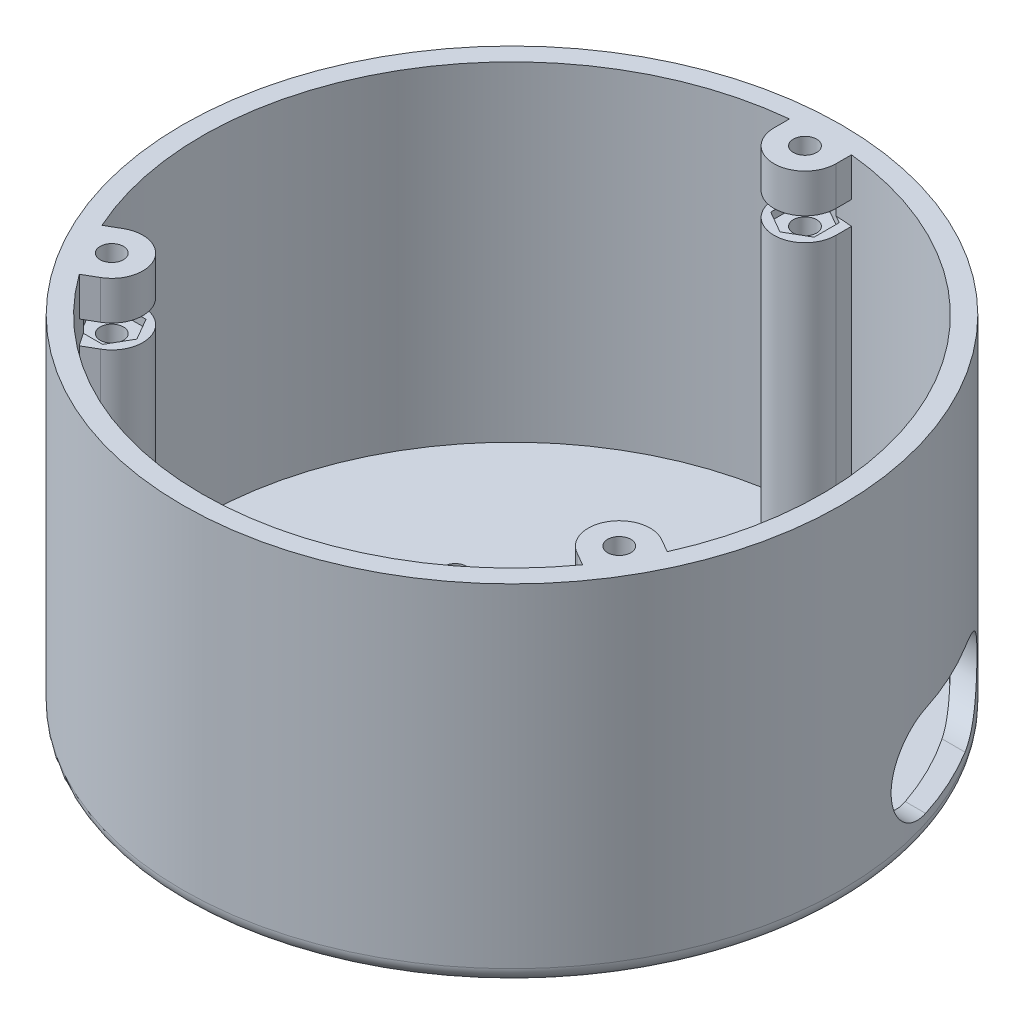
from build123d import *

# Parameters (mm, degrees)
SKETCH1_R           = 42.5
BOSS_EXTRUDE1_DEPTH = 45
FILLET1_R           = 2
SHELL1_T            = -2.5
SKETCH2_R           = 1.5
BOSS_EXTRUDE2_DEPTH = 42.5
CUT_EXTRUDE1_START  = -3
CUT_EXTRUDE1_DEPTH  = 6
CUT_EXTRUDE2_START  = -5
SKETCH4_R           = 40
CUT_EXTRUDE2_DEPTH  = 3
CUT_EXTRUDE3_DEPTH  = 120
SKETCH7_R           = 1.5
CUT_EXTRUDE4_DEPTH  = 10


with BuildPart() as part:
    # Sketch1 → Boss-Extrude1 (new body)
    with BuildSketch(Plane(origin=(0, 0, 0), x_dir=(1, 0, 0), z_dir=(0, 1, 0))):
        with Locations(Location((0, 0, 0), (0, 0, 90))):
            Circle(SKETCH1_R)
    extrude(amount=BOSS_EXTRUDE1_DEPTH)

    # Fillet1
    fillet1_edges = [part.edges().sort_by_distance(p)[0] for p in [
        (0, 0, 42.5),
    ]]
    fillet(fillet1_edges, radius=FILLET1_R)

    # Shell1
    shell1_openings = [part.faces().sort_by_distance(p)[0] for p in [
        (0, 45, 0),
    ]]
    offset(amount=SHELL1_T, openings=shell1_openings, kind=Kind.INTERSECTION)

    # Sketch2 → Boss-Extrude2 (add)
    with BuildSketch(Plane(origin=(0, 2.5, 0), x_dir=(1, 0, 0), z_dir=(0, 1, 0))):
        with BuildLine():
            Line((-34.080943597, -24.295444113), (-30.735760263, -22.364101615))
            ThreePointArc((-30.735760263, -22.364101615), (-29.271658648, -16.9), (-34.735760263, -15.435898385))
            Line((-34.735760263, -15.435898385), (-38.080943597, -17.367240883))
            Line((-38.080943597, -17.367240883), (-34.080943597, -24.295444113))
        make_face()
        with Locations(Location((-32.735760263, -18.9, 0), (0, 0, 90))):
            Circle(SKETCH2_R, mode=Mode.SUBTRACT)
        with BuildLine():
            Line((38.080943597, -17.367240883), (34.735760263, -15.435898385))
            ThreePointArc((34.735760263, -15.435898385), (29.271658648, -16.9), (30.735760263, -22.364101615))
            Line((30.735760263, -22.364101615), (34.080943597, -24.295444113))
            Line((34.080943597, -24.295444113), (38.080943597, -17.367240883))
        make_face()
        with Locations(Location((32.735760263, -18.9, 0), (0, 0, 90))):
            Circle(SKETCH2_R, mode=Mode.SUBTRACT)
        with BuildLine():
            Line((-4, 41.662684996), (-4, 37.8))
            ThreePointArc((-4, 37.8), (0, 33.8), (4, 37.8))
            Line((4, 37.8), (4, 41.662684996))
            Line((4, 41.662684996), (-4, 41.662684996))
        make_face()
        with Locations(Location((0, 37.8, 0), (0, 0, 90))):
            Circle(SKETCH2_R, mode=Mode.SUBTRACT)
    extrude(amount=BOSS_EXTRUDE2_DEPTH)

    # Sketch3 → Cut-Extrude1 (cut)
    with BuildSketch(Plane(origin=(0, 45, 0), x_dir=(1, 0, 0), z_dir=(0, 1, 0)).offset(CUT_EXTRUDE1_START)):
        Polygon((-31.119179509, -16.1), (-34.352341017, -16.1), (-35.968921771, -18.9), (-34.352341017, -21.7), (-31.119179509, -21.7), (-29.502598756, -18.9), align=None)
        Polygon((0, 41.033161507), (-2.8, 39.416580754), (-2.8, 36.183419246), (0, 34.566838493), (2.8, 36.183419246), (2.8, 39.416580754), align=None)
        Polygon((34.352341017, -16.1), (31.119179509, -16.1), (29.502598756, -18.9), (31.119179509, -21.7), (34.352341017, -21.7), (35.968921771, -18.9), align=None)
    extrude(amount=-CUT_EXTRUDE1_DEPTH, mode=Mode.SUBTRACT)

    # Sketch4 → Cut-Extrude2 (cut)
    with BuildSketch(Plane(origin=(0, 45, 0), x_dir=(1, 0, 0), z_dir=(0, 1, 0)).offset(CUT_EXTRUDE2_START)):
        Circle(SKETCH4_R)
    extrude(amount=-CUT_EXTRUDE2_DEPTH, mode=Mode.SUBTRACT)

    # Sketch6 → Cut-Extrude3 (cut)
    with BuildSketch(Plane(origin=(0, 0, 0), x_dir=(0, 0, -1), z_dir=(1, 0, 0))):
        with BuildLine():
            Line((12.858520148, 14.864349815), (22.241479852, 14.864349815))
            ThreePointArc((22.241479852, 14.864349815), (28.105829667, 9), (22.241479852, 3.135650185))
            Line((22.241479852, 3.135650185), (12.858520148, 3.135650185))
            ThreePointArc((12.858520148, 3.135650185), (6.994170333, 9), (12.858520148, 14.864349815))
        make_face()
    extrude(amount=CUT_EXTRUDE3_DEPTH, mode=Mode.SUBTRACT)

    # Sketch7 → Cut-Extrude4 (cut)
    with BuildSketch(Plane.XZ):
        with Locations(Location((17.320508076, -10, 0), (0, 0, 270))):
            Circle(SKETCH7_R)
        with Locations(Location((0, 20, 0), (0, 0, 270))):
            Circle(SKETCH7_R)
        with Locations(Location((-17.320508076, -10, 0), (0, 0, 270))):
            Circle(SKETCH7_R)
    extrude(amount=-CUT_EXTRUDE4_DEPTH, mode=Mode.SUBTRACT)


solid = part.part
